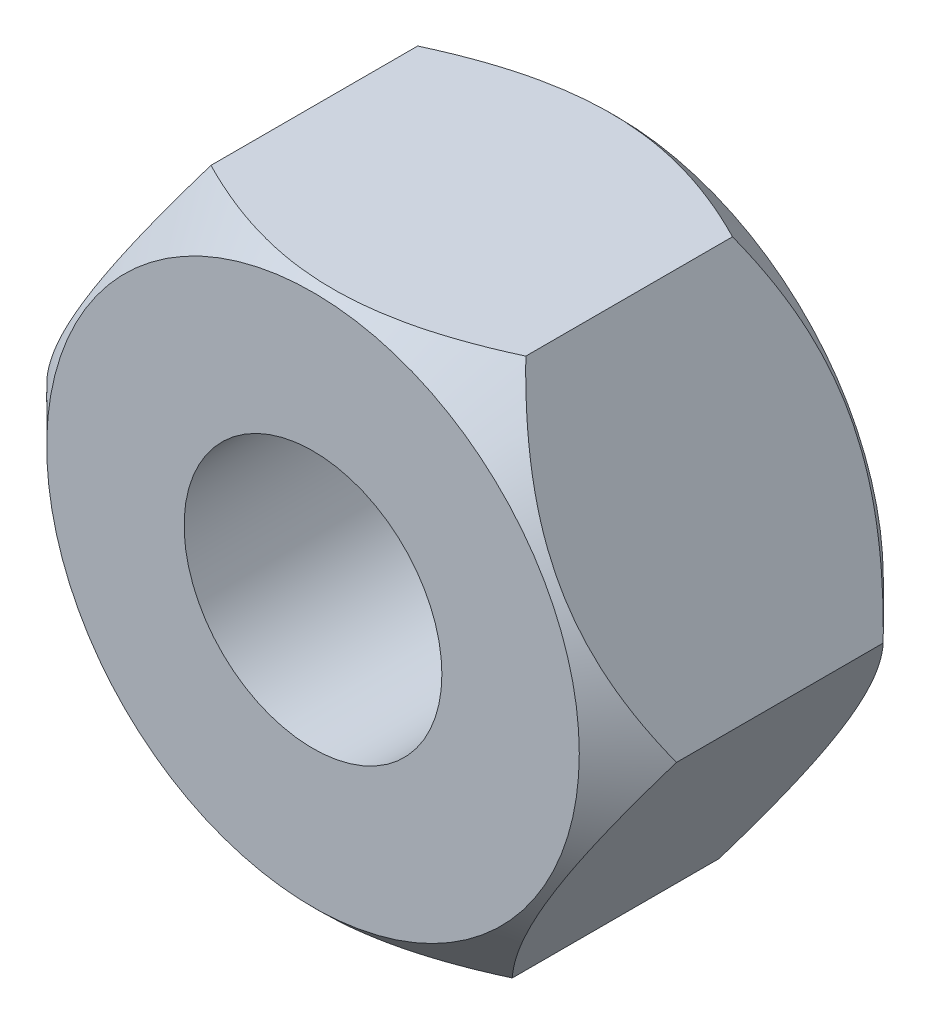
from build123d import *

# Parameters (mm, degrees)
SKETCH1_R           = 3.885
SKETCH1_R_2         = 1.59
BOSS_EXTRUDE1_DEPTH = 3.75
CHAMFER1_SIZE       = 0.6
CUT_EXTRUDE1_DEPTH  = 3.75


with BuildPart() as part:
    # Sketch1 → Boss-Extrude1 (new body)
    with BuildSketch(Plane.XY):
        Circle(SKETCH1_R)
        Circle(SKETCH1_R_2, mode=Mode.SUBTRACT)
    extrude(amount=BOSS_EXTRUDE1_DEPTH)

    # Chamfer1
    chamfer1_edges = [part.edges().sort_by_distance(p)[0] for p in [
        (-3.885, 0, 0),
        (-3.885, 0, 3.75),
    ]]
    chamfer(chamfer1_edges, length=CHAMFER1_SIZE)

    # Sketch2 → Cut-Extrude1 (cut)
    with BuildSketch(Plane(origin=(0, 0, 0), x_dir=(-1, 0, 0), z_dir=(0, 0, -1))):
        with BuildLine():
            Line((-3.883814063, -0.09598607), (-2.025033407, 3.315488607))
            ThreePointArc((-2.025033407, 3.315488607), (-3.411474677, 1.858780656), (-3.883814063, -0.09598607))
        make_face()
        with BuildLine():
            Line((-1.858780656, -3.411474677), (-3.883814063, -0.09598607))
            ThreePointArc((-3.883814063, -0.09598607), (-3.315488607, -2.025033407), (-1.858780656, -3.411474677))
        make_face()
        with BuildLine():
            ThreePointArc((-1.858780656, -3.411474677), (0.09598607, -3.883814063), (2.025033407, -3.315488607))
            Line((2.025033407, -3.315488607), (-1.858780656, -3.411474677))
        make_face()
        with BuildLine():
            ThreePointArc((3.885, 0), (3.884703504, 0.047996698), (3.883814063, 0.09598607))
            Line((3.883814063, 0.09598607), (2.025033407, -3.315488607))
            ThreePointArc((2.025033407, -3.315488607), (3.38825027, -1.900785392), (3.885, 0))
        make_face()
        with BuildLine():
            ThreePointArc((3.883814063, 0.09598607), (3.315488607, 2.025033407), (1.858780656, 3.411474677))
            Line((1.858780656, 3.411474677), (3.883814063, 0.09598607))
        make_face()
        with BuildLine():
            Line((-2.025033407, 3.315488607), (1.858780656, 3.411474677))
            ThreePointArc((1.858780656, 3.411474677), (-0.09598607, 3.883814063), (-2.025033407, 3.315488607))
        make_face()
    extrude(amount=-CUT_EXTRUDE1_DEPTH, mode=Mode.SUBTRACT)


solid = part.part
